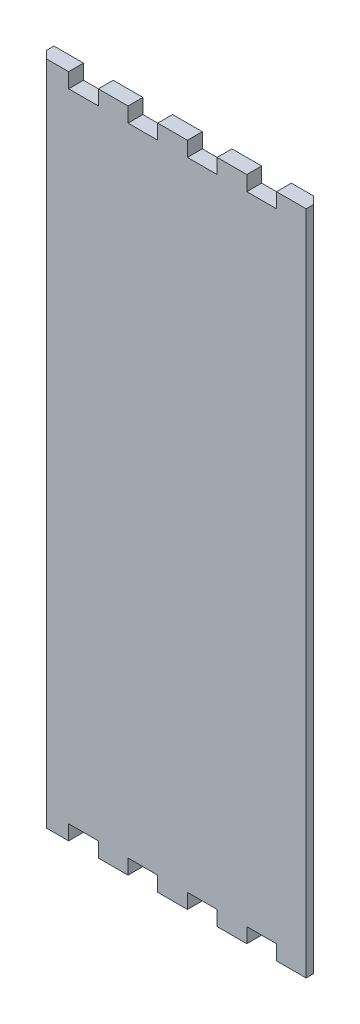
from build123d import *

# Parameters (mm, degrees)
BOSS_EXTRUDE1_DEPTH = 5.715
CUT_EXTRUDE1_DEPTH  = 257.4305006


with BuildPart() as part:
    # Model → Boss-Extrude1 (new body)
    with BuildSketch(Plane.XY):
        Polygon((861.0219, 23.2006394), (866.70388, 23.2006394), (866.70388, 28.91536), (878.13388, 28.91536), (878.13388, 23.2006394), (889.56896, 23.2006394), (889.56896, 28.91536), (900.99388, 28.91536), (900.99388, 23.2006394), (912.42896, 23.2006394), (912.42896, 28.91536), (923.85388, 28.91536), (923.85388, 23.2006394), (935.28388, 23.2006394), (935.28388, 28.91536), (946.71896, 28.91536), (946.71896, 23.2006394), (958.11594, 23.2006394), (958.11594, 279.63114), (946.71896, 279.63114), (946.71896, 273.91614), (935.28388, 273.91614), (935.28388, 279.63114), (923.85388, 279.63114), (923.85388, 273.91614), (912.42896, 273.91614), (912.42896, 279.63114), (900.99388, 279.63114), (900.99388, 273.91614), (889.56896, 273.91614), (889.56896, 279.63114), (878.13388, 279.63114), (878.13388, 273.91614), (866.70388, 273.91614), (866.70388, 279.63114), (855.3069, 279.63114), (855.3069, 23.2006394), align=None)
    extrude(amount=BOSS_EXTRUDE1_DEPTH)

    # Sketch1 → Cut-Extrude1 (cut, through all)
    with BuildSketch(Plane.XZ.offset(-23.2006394)):
        Polygon((855.3069, 2.8575), (858.1644, 5.715), (855.3069, 5.715), align=None)
        Polygon((958.11594, 2.8575), (955.25844, 0), (958.11594, 0), align=None)
    extrude(amount=-CUT_EXTRUDE1_DEPTH, mode=Mode.SUBTRACT)


solid = part.part
